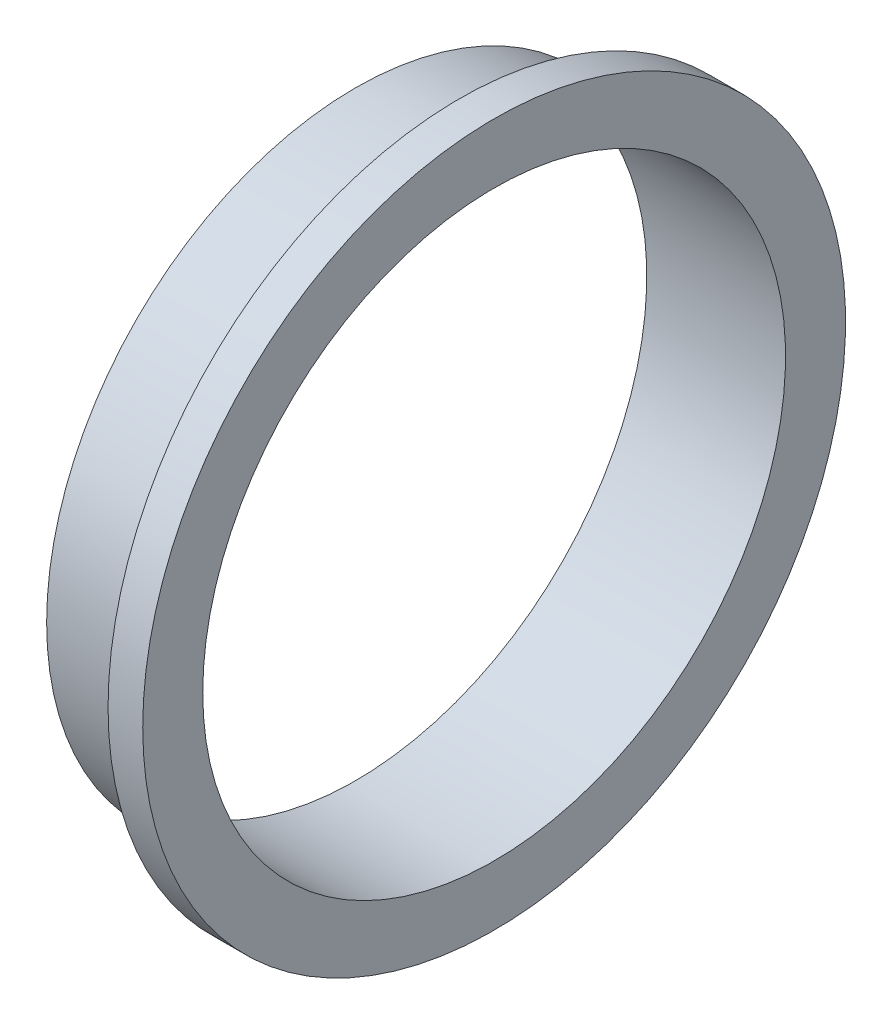
from build123d import *


with BuildPart() as part:
    # Sketch1 → Revolve1 (revolve)
    with BuildSketch(Plane.XY):
        Polygon((0, 89), (30, 89), (30, 101.3), (40, 101.3), (40, 84), (0, 84), align=None)
    revolve(axis=Axis((-2, 0, 0), (1, 0, 0)))


solid = part.part
